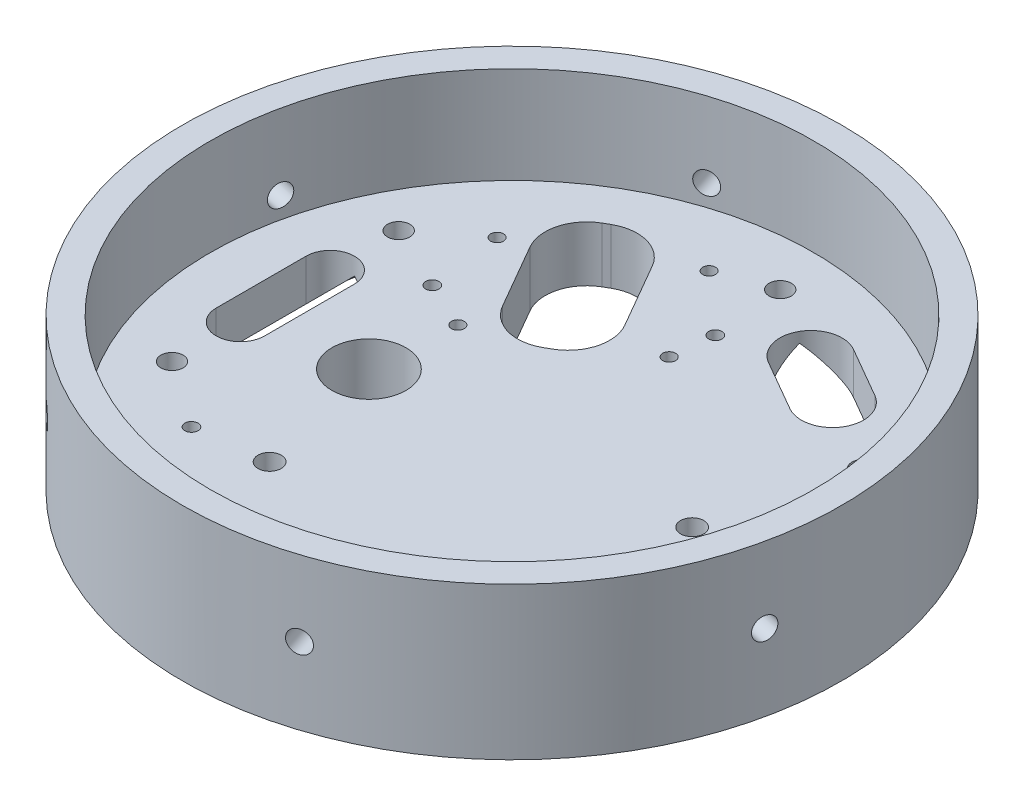
from build123d import *

# Parameters (mm, degrees)
SKETCH1_R                            = 75.692
SKETCH1_R_2                          = 69.342
BOSS_EXTRUDE1_DEPTH                  = 22.225
BOSS_EXTRUDE2_START                  = 12.7
SKETCH2_R                            = 75.692
BOSS_EXTRUDE2_DEPTH                  = 12.7
TAP_DRILL_FOR_1_4_20_TAP1_AT_2_COUNT = 2
TAP_DRILL_FOR_1_4_20_TAP1_AT_2_PITCH = 53.488399339
CIRPATTERN1_COUNT                    = 6
SKETCH6_R                            = 2.667
CUT_EXTRUDE1_DEPTH                   = 110.327528042
CHAMFER1_SIZE                        = 3.175
CUT_EXTRUDE2_DEPTH                   = 22.225
CUT_EXTRUDE2_DEPTH_BACK              = 22.225
F_1_4_20_TAPPED_HOLE1_D              = 5.1054
SKETCH22_R                           = 1.4732
SKETCH22_R_2                         = 2.667
CUT_EXTRUDE3_DEPTH                   = 77.47
SKETCH23_R                           = 1.4732
SKETCH23_R_2                         = 8.509
CUT_EXTRUDE4_DEPTH                   = 12.7
FILLET2_R                            = 9.525
TAPPED_HOLE_FOR_4_40_HELICOIL1_D     = 3.048


with BuildPart() as part:
    # Sketch1 → Boss-Extrude1 (new body)
    with BuildSketch(Plane(origin=(0, 0, 0), x_dir=(1, 0, 0), z_dir=(0, 1, 0))):
        with Locations(Location((0, 0, 0), (0, 0, 270))):
            Circle(SKETCH1_R)
        with Locations(Location((0, 0, 0), (0, 0, 270))):
            Circle(SKETCH1_R_2, mode=Mode.SUBTRACT)
    extrude(amount=BOSS_EXTRUDE1_DEPTH)

    # Sketch2 → Boss-Extrude2 (add)
    with BuildSketch(Plane.XZ.offset(BOSS_EXTRUDE2_START)):
        with Locations(Location((0, 0, 0), (0, 0, 270))):
            Circle(SKETCH2_R)
    extrude(amount=-BOSS_EXTRUDE2_DEPTH)

    # Sketch4 → Tap Drill for 1/4-20 Tap1 (revolve, cut)
    with BuildSketch(Plane(origin=(73.997176623, 4.896298223, 15.927859738), x_dir=(0.21042989666546502, 0, -0.9776089497285517), z_dir=(0, 1, 0))):
        Polygon((0, 0), (0, 11.185816902), (2.5527, 9.652), (2.5527, 0), align=None)
    tap_drill_for_1_4_20_tap1 = revolve(axis=Axis((80.204993454, 4.896298223, 17.264089582), (-0.9776089497285516, 0, -0.210429896665465)), mode=Mode.SUBTRACT)

    # Tap Drill for 1/4-20 Tap1 at 2: Tap Drill for 1/4-20 Tap1 ×2
    with Locations(*[Vector(-0.1104385806360645, 0.8512109993044242, 0.5130722703189632) * (i * TAP_DRILL_FOR_1_4_20_TAP1_AT_2_PITCH) for i in range(1, TAP_DRILL_FOR_1_4_20_TAP1_AT_2_COUNT)]):
        add(tap_drill_for_1_4_20_tap1, mode=Mode.SUBTRACT)

    # CirPattern1: Tap Drill for 1/4-20 Tap1 ×6 about axis
    cirpattern1_axis = Axis((0, 22.225, 0), (0, -1, 0))
    for i in range(1, CIRPATTERN1_COUNT):
        add(tap_drill_for_1_4_20_tap1.rotate(cirpattern1_axis, i * 360 / CIRPATTERN1_COUNT), mode=Mode.SUBTRACT)

    # CirPattern1 copy 1 sketch → CirPattern1 copy 1 (revolve, cut)
    with BuildSketch(Plane(origin=(-3.515628412, 50.426212075, 80.653301416), x_dir=(0.9518491337646824, 0, -0.30656683863624895), z_dir=(0, 1, 0))):
        Polygon((0, 0), (0, 11.185816902), (2.5527, 9.652), (2.5527, 0), align=None)
    revolve(axis=Axis((-1.568928987, 50.426212075, 86.697543415), (-0.3065668386362489, 0, -0.9518491337646823)), mode=Mode.SUBTRACT)

    # CirPattern1 copy 2 sketch → CirPattern1 copy 2 (revolve, cut)
    with BuildSketch(Plane(origin=(-71.605622131, 50.426212075, 37.282027193), x_dir=(0.7414192370992175, 0, 0.6710421110923027), z_dir=(0, 1, 0))):
        Polygon((0, 0), (0, 11.185816902), (2.5527, 9.652), (2.5527, 0), align=None)
    revolve(axis=Axis((-75.866739537, 50.426212075, 41.990039348), (0.6710421110923026, 0, -0.7414192370992174)), mode=Mode.SUBTRACT)

    # CirPattern1 copy 3 sketch → CirPattern1 copy 3 (revolve, cut)
    with BuildSketch(Plane(origin=(-68.089993719, 50.426212075, -43.371274223), x_dir=(-0.2104298966654649, 0, 0.9776089497285517), z_dir=(0, 1, 0))):
        Polygon((0, 0), (0, 11.185816902), (2.5527, 9.652), (2.5527, 0), align=None)
    revolve(axis=Axis((-74.29781055, 50.426212075, -44.707504067), (0.9776089497285516, 0, 0.21042989666546488)), mode=Mode.SUBTRACT)

    # CirPattern1 copy 4 sketch → CirPattern1 copy 4 (revolve, cut)
    with BuildSketch(Plane(origin=(3.515628412, 50.426212075, -80.653301416), x_dir=(-0.9518491337646823, 0, 0.30656683863624934), z_dir=(0, 1, 0))):
        Polygon((0, 0), (0, 11.185816902), (2.5527, 9.652), (2.5527, 0), align=None)
    revolve(axis=Axis((1.568928987, 50.426212075, -86.697543415), (0.3065668386362493, 0, 0.9518491337646823)), mode=Mode.SUBTRACT)

    # CirPattern1 copy 5 sketch → CirPattern1 copy 5 (revolve, cut)
    with BuildSketch(Plane(origin=(71.605622131, 50.426212075, -37.282027193), x_dir=(-0.7414192370992174, 0, -0.671042111092303), z_dir=(0, 1, 0))):
        Polygon((0, 0), (0, 11.185816902), (2.5527, 9.652), (2.5527, 0), align=None)
    revolve(axis=Axis((75.866739537, 50.426212075, -41.990039348), (-0.6710421110923029, 0, 0.7414192370992173)), mode=Mode.SUBTRACT)

    # Sketch6 → Cut-Extrude1 (cut, through all)
    with BuildSketch(Plane(origin=(0, 0, 0), x_dir=(1, 0, 0), z_dir=(0, 1, 0))):
        with Locations(Location((40.633241058, 0.741162011, 0), (0, 0, 270))):
            Circle(SKETCH6_R)
        with Locations(Location((50.158241058, -15.756621931, 0), (0, 0, 270))):
            Circle(SKETCH6_R)
        with BuildLine():
            Line((-57.62625, -10.31875), (-57.62625, 10.31875))
            ThreePointArc((-57.62625, 10.31875), (-52.07, 15.875), (-46.51375, 10.31875))
            Line((-46.51375, 10.31875), (-46.51375, -10.31875))
            ThreePointArc((-46.51375, -10.31875), (-52.07, -15.875), (-57.62625, -10.31875))
        make_face()
        with BuildLine():
            Line((28.306090146, 35.533836297), (16.620159854, 42.280711297))
            ThreePointArc((16.620159854, 42.280711297), (14.005365876, 52.039255275), (23.763909854, 54.654049253))
            Line((23.763909854, 54.654049253), (35.449840146, 47.907174253))
            ThreePointArc((35.449840146, 47.907174253), (38.064634124, 38.148630275), (28.306090146, 35.533836297))
        make_face()
    extrude(amount=-CUT_EXTRUDE1_DEPTH, mode=Mode.SUBTRACT)

    # Chamfer1
    chamfer1_edges = [part.edges().sort_by_distance(p)[0] for p in [
        (-52.07, -12.7, 15.875),
        (-57.62625, -12.7, 0),
        (-52.07, -12.7, -15.875),
        (-46.51375, -12.7, 0),
        (38.064634124, -12.7, -38.148630275),
        (22.463125, -12.7, -38.907273797),
        (14.005365876, -12.7, -52.039255275),
        (29.606875, -12.7, -51.280611753),
    ]]
    chamfer(chamfer1_edges, length=CHAMFER1_SIZE)

    # Sketch7 → Cut-Extrude2 (cut, two sides: drawn at the far end of the back side and taken through both)
    with BuildSketch(Plane.XY.offset(-CUT_EXTRUDE2_DEPTH_BACK)):
        Polygon((-43.33875, -12.7), (-52.07, -3.96875), (-60.80125, -12.7), align=None)
    extrude(amount=CUT_EXTRUDE2_DEPTH + CUT_EXTRUDE2_DEPTH_BACK, mode=Mode.SUBTRACT)

    # Sketch8 → Cut-Revolve1 (revolve, cut)
    with BuildSketch(Plane(origin=(0, 0, 22.225), x_dir=(-1, 0, 0), z_dir=(0, 0, -1))):
        Polygon((52.07, -3.96875), (52.07, -12.7), (43.33875, -12.7), align=None)
    revolve(axis=Axis((-52.07, -3.96875, 22.225), (0, -1, 0)), mode=Mode.SUBTRACT)

    # Sketch9 → Cut-Revolve2 (revolve, cut)
    with BuildSketch(Plane.XY.offset(-22.225)):
        Polygon((-52.07, -3.96875), (-52.07, -12.7), (-60.80125, -12.7), align=None)
    revolve(axis=Axis((-52.07, -3.96875, -22.225), (0, -1, 0)), mode=Mode.SUBTRACT)

    # Cut-Sweep1: sweep along a path in Sketch10
    with BuildLine(Plane.XZ.offset(12.7)) as cut_sweep1_path:
        Line((45.282414599, -33.981442775), (6.787585401, -56.206442775))
    # 3DSketch4 → Cut-Sweep1 (sweep, cut)
    with BuildSketch(Plane(origin=(20.875625002, -12.7, -36.157643139), x_dir=(0.5000000000000027, 0, -0.8660254037844372), z_dir=(0.8660254037844372, 1.3449097814962572e-15, 0.5000000000000027))):
        Polygon((0, 0), (10.31875, 10.31875), (20.6375, 0), align=None)
    sweep(path=cut_sweep1_path.line, mode=Mode.SUBTRACT)

    # Sketch11 → Cut-Revolve3 (revolve, cut)
    with BuildSketch(Plane(origin=(-19.247414599, 0, -11.1125), x_dir=(0.5000000000000028, 0, -0.8660254037844372), z_dir=(0.866025403784437, 1.4915878357495889e-15, 0.5000000000000027))):
        Polygon((41.75125, -12.7), (52.07, -2.38125), (52.07, -12.7), align=None)
    revolve(axis=Axis((6.787585401, -12.7, -56.206442775), (0, 1, 0)), mode=Mode.SUBTRACT)

    # Sketch12 → Cut-Revolve4 (revolve, cut)
    with BuildSketch(Plane(origin=(19.247414599, 0, 11.1125), x_dir=(-0.5000000000000028, 0, 0.8660254037844372), z_dir=(-0.866025403784437, -1.4915878357495889e-15, -0.5000000000000027))):
        Polygon((-52.07, -2.38125), (-62.38875, -12.7), (-52.07, -12.7), align=None)
    revolve(axis=Axis((45.282414599, -12.7, -33.981442775), (0, 1, 0)), mode=Mode.SUBTRACT)

    # 1/4-20 Tapped Hole1 (through all)
    with Locations(Plane(origin=(0, 0, 0), x_dir=(1, 0, 0), z_dir=(0, 1, 0))):
        with Locations((-52.07, 26.035), (-52.07, -26.035), (48.581971388, 32.076442775), (3.488028612, 58.111442775)):
            Hole(F_1_4_20_TAPPED_HOLE1_D / 2)

    # Sketch22 → Cut-Extrude3 (cut)
    with BuildSketch(Plane(origin=(0, 0, 0), x_dir=(1, 0, 0), z_dir=(0, 1, 0))):
        with Locations(Location((-39.400421517, 35.961622193, 0), (0, 0, 270))):
            Circle(SKETCH22_R)
        with Locations(Location((-26.496046543, 14.064298929, 0), (0, 0, 270))):
            Circle(SKETCH22_R)
        with Locations(Location((4.124869054, 31.97437775, 0), (0, 0, 270))):
            Circle(SKETCH22_R)
        with Locations(Location((-8.411932719, 53.683744769, 0), (0, 0, 270))):
            Circle(SKETCH22_R)
        with Locations(Location((-20.898670532, -34.784303709, 0), (0, 0, 270))):
            Circle(SKETCH22_R_2)
        with Locations(Location((-11.373670532, -51.282087651, 0), (0, 0, 270))):
            Circle(SKETCH22_R_2)
    extrude(amount=-CUT_EXTRUDE3_DEPTH, mode=Mode.SUBTRACT)

    # Sketch23 → Cut-Extrude4 (cut)
    with BuildSketch(Plane(origin=(0, 0, 0), x_dir=(1, 0, 0), z_dir=(0, 1, 0))):
        with Locations(Location((-8.411932719, 53.683744769, 0), (0, 0, 270))):
            Circle(SKETCH23_R)
        with Locations(Location((4.124869054, 31.97437775, 0), (0, 0, 270))):
            Circle(SKETCH23_R)
        with Locations(Location((-26.496046543, 14.064298929, 0), (0, 0, 270))):
            Circle(SKETCH23_R)
        with Locations(Location((-39.400421517, 35.961622193, 0), (0, 0, 270))):
            Circle(SKETCH23_R)
        with Locations(Location((-27.94, -4.926575841, 0), (0, 0, 270))):
            Circle(SKETCH23_R_2)
        Polygon((-20.338803329, 14.653840731), (-2.521196671, 24.940840731), (-20.682196671, 56.396615447), (-38.499803329, 46.109615447), align=None)
    extrude(amount=-CUT_EXTRUDE4_DEPTH, mode=Mode.SUBTRACT)

    # Fillet2
    fillet2_edges = [part.edges().sort_by_distance(p)[0] for p in [
        (-20.338803329, -6.35, -14.653840731),
        (-38.499803329, -6.35, -46.109615447),
        (-20.682196671, -6.35, -56.396615447),
        (-2.521196671, -6.35, -24.940840731),
    ]]
    fillet(fillet2_edges, radius=FILLET2_R)

    # Tapped Hole for #4-40 Helicoil1 (through all)
    with Locations(Plane(origin=(0, -12.7, 0), x_dir=(-1, 0, 0), z_dir=(0, -1, 0))):
        with Locations((37.342083429, 19.026741844), (-5.107544182, 41.597609215), (-50.295757775, 13.476707678), (36.819050096, -36.819050096)):
            Hole(TAPPED_HOLE_FOR_4_40_HELICOIL1_D / 2)


solid = part.part
